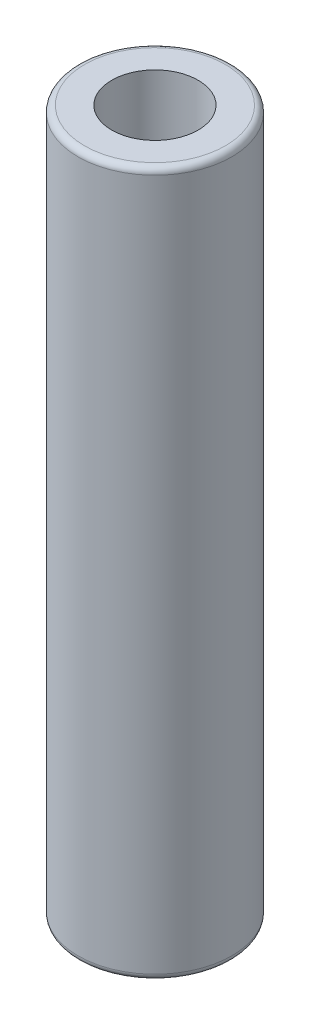
from build123d import *

# Parameters (mm, degrees)
F_1_2_13_TAPPED_HOLE1_D     = 10.71626
F_1_2_13_TAPPED_HOLE1_DEPTH = 19.05
F_1_2_13_TAPPED_HOLE1_TIP   = 3.219489309


with BuildPart() as part:
    # Sketch1 → Revolve1 (revolve)
    with BuildSketch(Plane.XY):
        with BuildLine():
            Line((0, 0), (0, 43.6753))
            Line((0, 43.6753), (8.73125, 43.6753))
            ThreePointArc((8.73125, 43.6753), (9.292516008, 43.442816008), (9.525, 42.88155))
            Line((9.525, 42.88155), (9.525, 0.79375))
            Line((9.525, 0.79375), (9.525, 0))
            Line((9.525, 0), (0, 0))
        make_face()
    revolve(axis=Axis((0, 288.392157732, 0), (0, -1, 0)))

    # 1/2-13 Tapped Hole1
    with Locations(Plane(origin=(0, 43.6753, 0), x_dir=(1, 0, 0), z_dir=(0, 1, 0))):
        with Locations((0, 0)):
            Hole(F_1_2_13_TAPPED_HOLE1_D / 2, depth=F_1_2_13_TAPPED_HOLE1_DEPTH)
            with Locations((0, 0, -(F_1_2_13_TAPPED_HOLE1_DEPTH + F_1_2_13_TAPPED_HOLE1_TIP / 2))):  # 118° drill point
                Cone(0, F_1_2_13_TAPPED_HOLE1_D / 2, F_1_2_13_TAPPED_HOLE1_TIP, mode=Mode.SUBTRACT)

    # Mirror1: part across plane


with BuildPart() as part_1:
    add(part.part)
    add(part.part.mirror(Plane.ZX))


solid = part_1.part
